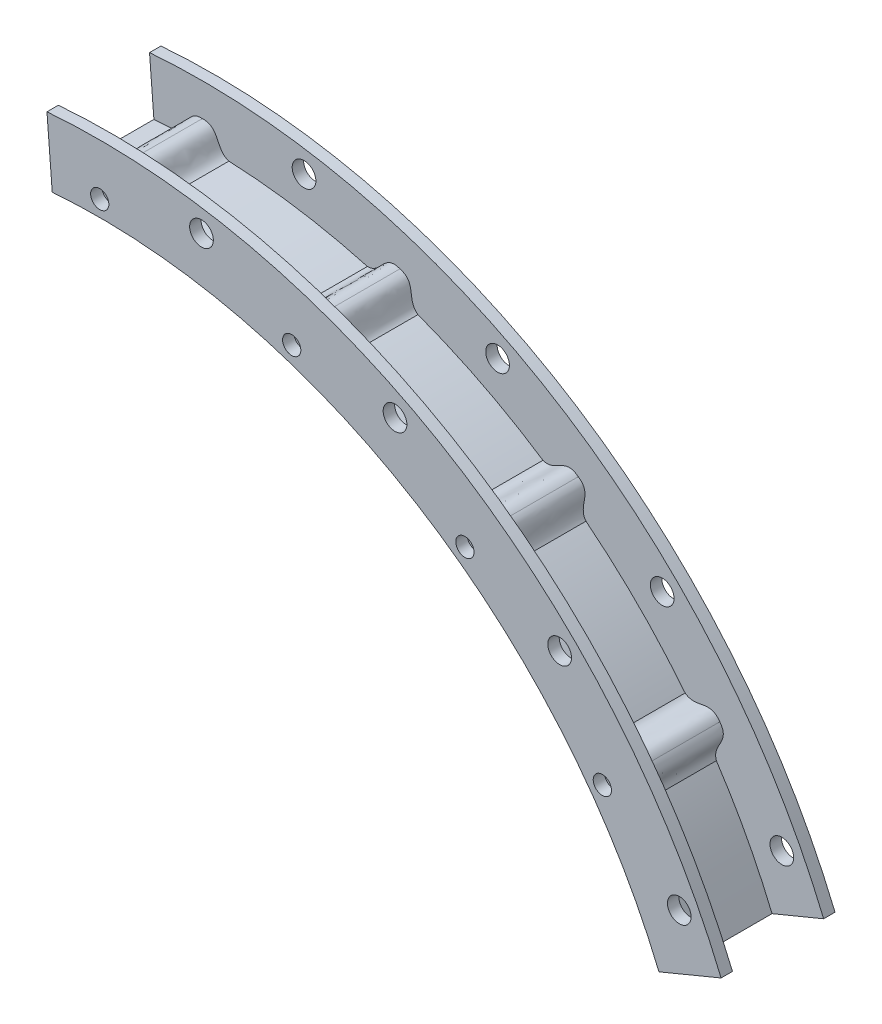
from build123d import *

# Parameters (mm, degrees)
SKETCH2_R              = 187.3885
SKETCH2_R_2            = 168.656
BOSS_EXTRUDE1_DEPTH    = 3.175
SKETCH3_R              = 171.831
SKETCH3_R_2            = 168.656
BOSS_EXTRUDE2_DEPTH    = 25.4
SKETCH4_R              = 187.3885
SKETCH4_R_2            = 168.656
BOSS_EXTRUDE3_DEPTH    = 3.175
SKETCH5_R              = 1.27
BOSS_EXTRUDE4_DEPTH    = 30.48
SKETCH6_R              = 2.54
CUT_EXTRUDE3_DEPTH     = 3.175
SKETCH7_R              = 3.302
CUT_EXTRUDE4_DEPTH     = 267.902533595
SPLIT1_SURFACE_1_BACK  = 531.965
SPLIT1_SURFACE_1_DEPTH = 1063.93


with BuildPart() as part:
    # Sketch2 → Boss-Extrude1 (new body)
    with BuildSketch(Plane.XY):
        Circle(SKETCH2_R)
        Circle(SKETCH2_R_2, mode=Mode.SUBTRACT)
    extrude(amount=BOSS_EXTRUDE1_DEPTH)

    # Sketch3 → Boss-Extrude2 (add)
    with BuildSketch(Plane.XY.offset(3.175)):
        Circle(SKETCH3_R)
        Circle(SKETCH3_R_2, mode=Mode.SUBTRACT)
    extrude(amount=BOSS_EXTRUDE2_DEPTH)

    # Sketch4 → Boss-Extrude3 (add)
    with BuildSketch(Plane.XY.offset(28.575)):
        Circle(SKETCH4_R)
        Circle(SKETCH4_R_2, mode=Mode.SUBTRACT)
    extrude(amount=BOSS_EXTRUDE3_DEPTH)

    # Sketch5 → Boss-Extrude4 (add)
    with BuildSketch(Plane.XY.offset(31.75)):
        with BuildLine():
            Line((-7.405015197, 171.671367184), (7.405015197, 171.671367184))
            add(Edge.make_bspline(
                [(0, 178.234154253), (4.961940314, 178.4344709), (3.628279784, 172.828030111), (7.405015197, 171.671367184)],
                knots=[0, 0, 0, 0, 1, 1, 1, 1], degree=3))
            add(Edge.make_bspline(
                [(0, 178.234154253), (-4.961940314, 178.4344709), (-3.628279784, 172.828030111), (-7.405015197, 171.671367184)],
                knots=[0, 0, 0, 0, 1, 1, 1, 1], degree=3))
        make_face()
        with Locations((0, 173.101)):
            Circle(SKETCH5_R, mode=Mode.SUBTRACT)
        with BuildLine():
            Line((46.006781951, 165.557447961), (60.091957864, 160.980896883))
            add(Edge.make_bspline(
                [(55.077382642, 169.510753828), (59.858369559, 168.167942399), (56.85749754, 163.248024122), (60.091957864, 160.980896883)],
                knots=[0, 0, 0, 0, 1, 1, 1, 1], degree=3))
            add(Edge.make_bspline(
                [(55.077382642, 169.510753828), (50.420198222, 171.234590163), (49.956099277, 165.490424349), (46.006781951, 165.557447961)],
                knots=[0, 0, 0, 0, 1, 1, 1, 1], degree=3))
        make_face()
        with Locations((53.491150743, 164.628834027)):
            Circle(SKETCH5_R, mode=Mode.SUBTRACT)
        with BuildLine():
            Line((94.915114734, 143.237612225), (106.89668101, 134.532494774))
            add(Edge.make_bspline(
                [(104.763407324, 144.194459768), (108.895444535, 141.439964002), (104.521107288, 137.688164116), (106.89668101, 134.532494774)],
                knots=[0, 0, 0, 0, 1, 1, 1, 1], degree=3))
            add(Edge.make_bspline(
                [(104.763407324, 144.194459768), (100.866856457, 147.27307468), (98.650427276, 141.953462812), (94.915114734, 143.237612225)],
                knots=[0, 0, 0, 0, 1, 1, 1, 1], degree=3))
        make_face()
        with Locations((101.746214957, 140.041650743)):
            Circle(SKETCH5_R, mode=Mode.SUBTRACT)
        with BuildLine():
            Line((134.532494774, 106.89668101), (143.237612225, 94.915114734))
            add(Edge.make_bspline(
                [(144.194459768, 104.763407324), (147.27307468, 100.866856457), (141.953462812, 98.650427276), (143.237612225, 94.915114734)],
                knots=[0, 0, 0, 0, 1, 1, 1, 1], degree=3))
            add(Edge.make_bspline(
                [(144.194459768, 104.763407324), (141.439964002, 108.895444535), (137.688164116, 104.521107288), (134.532494774, 106.89668101)],
                knots=[0, 0, 0, 0, 1, 1, 1, 1], degree=3))
        make_face()
        with Locations((140.041650743, 101.746214957)):
            Circle(SKETCH5_R, mode=Mode.SUBTRACT)
        with BuildLine():
            Line((160.980896883, 60.091957864), (165.557447961, 46.006781951))
            add(Edge.make_bspline(
                [(169.510753828, 55.077382642), (171.234590163, 50.420198222), (165.490424349, 49.956099277), (165.557447961, 46.006781951)],
                knots=[0, 0, 0, 0, 1, 1, 1, 1], degree=3))
            add(Edge.make_bspline(
                [(169.510753828, 55.077382642), (168.167942399, 59.858369559), (163.248024122, 56.85749754), (160.980896883, 60.091957864)],
                knots=[0, 0, 0, 0, 1, 1, 1, 1], degree=3))
        make_face()
        with Locations((164.628834027, 53.491150743)):
            Circle(SKETCH5_R, mode=Mode.SUBTRACT)
        with BuildLine():
            Line((171.671367184, 7.405015197), (171.671367184, -7.405015197))
            add(Edge.make_bspline(
                [(178.234154253, 0), (178.4344709, -4.961940314), (172.828030111, -3.628279784), (171.671367184, -7.405015197)],
                knots=[0, 0, 0, 0, 1, 1, 1, 1], degree=3))
            add(Edge.make_bspline(
                [(178.234154253, 0), (178.4344709, 4.961940314), (172.828030111, 3.628279784), (171.671367184, 7.405015197)],
                knots=[0, 0, 0, 0, 1, 1, 1, 1], degree=3))
        make_face()
        with Locations((173.101, 0)):
            Circle(SKETCH5_R, mode=Mode.SUBTRACT)
        with BuildLine():
            Line((165.557447961, -46.006781951), (160.980896883, -60.091957864))
            add(Edge.make_bspline(
                [(169.510753828, -55.077382642), (168.167942399, -59.858369559), (163.248024122, -56.85749754), (160.980896883, -60.091957864)],
                knots=[0, 0, 0, 0, 1, 1, 1, 1], degree=3))
            add(Edge.make_bspline(
                [(169.510753828, -55.077382642), (171.234590163, -50.420198222), (165.490424349, -49.956099277), (165.557447961, -46.006781951)],
                knots=[0, 0, 0, 0, 1, 1, 1, 1], degree=3))
        make_face()
        with Locations((164.628834027, -53.491150743)):
            Circle(SKETCH5_R, mode=Mode.SUBTRACT)
        with BuildLine():
            Line((143.237612225, -94.915114734), (134.532494774, -106.89668101))
            add(Edge.make_bspline(
                [(144.194459768, -104.763407324), (141.439964002, -108.895444535), (137.688164116, -104.521107288), (134.532494774, -106.89668101)],
                knots=[0, 0, 0, 0, 1, 1, 1, 1], degree=3))
            add(Edge.make_bspline(
                [(144.194459768, -104.763407324), (147.27307468, -100.866856457), (141.953462812, -98.650427276), (143.237612225, -94.915114734)],
                knots=[0, 0, 0, 0, 1, 1, 1, 1], degree=3))
        make_face()
        with Locations((140.041650743, -101.746214957)):
            Circle(SKETCH5_R, mode=Mode.SUBTRACT)
        with BuildLine():
            Line((106.89668101, -134.532494774), (94.915114734, -143.237612225))
            add(Edge.make_bspline(
                [(104.763407324, -144.194459768), (100.866856457, -147.27307468), (98.650427276, -141.953462813), (94.915114734, -143.237612225)],
                knots=[0, 0, 0, 0, 1, 1, 1, 1], degree=3))
            add(Edge.make_bspline(
                [(104.763407324, -144.194459768), (108.895444535, -141.439964002), (104.521107288, -137.688164116), (106.89668101, -134.532494774)],
                knots=[0, 0, 0, 0, 1, 1, 1, 1], degree=3))
        make_face()
        with Locations((101.746214957, -140.041650743)):
            Circle(SKETCH5_R, mode=Mode.SUBTRACT)
        with BuildLine():
            Line((60.091957864, -160.980896883), (46.006781951, -165.557447961))
            add(Edge.make_bspline(
                [(55.077382642, -169.510753828), (50.420198222, -171.234590163), (49.956099277, -165.490424349), (46.006781951, -165.557447961)],
                knots=[0, 0, 0, 0, 1, 1, 1, 1], degree=3))
            add(Edge.make_bspline(
                [(55.077382642, -169.510753828), (59.858369559, -168.167942399), (56.85749754, -163.248024122), (60.091957864, -160.980896883)],
                knots=[0, 0, 0, 0, 1, 1, 1, 1], degree=3))
        make_face()
        with Locations((53.491150743, -164.628834027)):
            Circle(SKETCH5_R, mode=Mode.SUBTRACT)
        with BuildLine():
            Line((7.405015197, -171.671367184), (-7.405015197, -171.671367184))
            add(Edge.make_bspline(
                [(0, -178.234154253), (-4.961940314, -178.4344709), (-3.628279784, -172.828030111), (-7.405015197, -171.671367184)],
                knots=[0, 0, 0, 0, 1, 1, 1, 1], degree=3))
            add(Edge.make_bspline(
                [(0, -178.234154253), (4.961940314, -178.4344709), (3.628279784, -172.828030111), (7.405015197, -171.671367184)],
                knots=[0, 0, 0, 0, 1, 1, 1, 1], degree=3))
        make_face()
        with Locations((0, -173.101)):
            Circle(SKETCH5_R, mode=Mode.SUBTRACT)
        with BuildLine():
            Line((-46.006781951, -165.557447961), (-60.091957864, -160.980896883))
            add(Edge.make_bspline(
                [(-55.077382642, -169.510753828), (-59.858369559, -168.167942399), (-56.85749754, -163.248024122), (-60.091957864, -160.980896883)],
                knots=[0, 0, 0, 0, 1, 1, 1, 1], degree=3))
            add(Edge.make_bspline(
                [(-55.077382642, -169.510753828), (-50.420198222, -171.234590163), (-49.956099277, -165.490424349), (-46.006781951, -165.557447961)],
                knots=[0, 0, 0, 0, 1, 1, 1, 1], degree=3))
        make_face()
        with Locations((-53.491150743, -164.628834027)):
            Circle(SKETCH5_R, mode=Mode.SUBTRACT)
        with BuildLine():
            Line((-94.915114734, -143.237612225), (-106.89668101, -134.532494774))
            add(Edge.make_bspline(
                [(-104.763407324, -144.194459768), (-108.895444535, -141.439964002), (-104.521107288, -137.688164116), (-106.89668101, -134.532494774)],
                knots=[0, 0, 0, 0, 1, 1, 1, 1], degree=3))
            add(Edge.make_bspline(
                [(-104.763407324, -144.194459768), (-100.866856457, -147.27307468), (-98.650427276, -141.953462812), (-94.915114734, -143.237612225)],
                knots=[0, 0, 0, 0, 1, 1, 1, 1], degree=3))
        make_face()
        with Locations((-101.746214957, -140.041650743)):
            Circle(SKETCH5_R, mode=Mode.SUBTRACT)
        with BuildLine():
            Line((-134.532494774, -106.89668101), (-143.237612225, -94.915114734))
            add(Edge.make_bspline(
                [(-144.194459768, -104.763407324), (-147.27307468, -100.866856457), (-141.953462813, -98.650427276), (-143.237612225, -94.915114734)],
                knots=[0, 0, 0, 0, 1, 1, 1, 1], degree=3))
            add(Edge.make_bspline(
                [(-144.194459768, -104.763407324), (-141.439964001, -108.895444535), (-137.688164116, -104.521107288), (-134.532494774, -106.89668101)],
                knots=[0, 0, 0, 0, 1, 1, 1, 1], degree=3))
        make_face()
        with Locations((-140.041650743, -101.746214957)):
            Circle(SKETCH5_R, mode=Mode.SUBTRACT)
        with BuildLine():
            Line((-160.980896882, -60.091957864), (-165.557447961, -46.006781951))
            add(Edge.make_bspline(
                [(-169.510753828, -55.077382642), (-171.234590163, -50.420198222), (-165.490424349, -49.956099277), (-165.557447961, -46.006781951)],
                knots=[0, 0, 0, 0, 1, 1, 1, 1], degree=3))
            add(Edge.make_bspline(
                [(-169.510753828, -55.077382642), (-168.167942399, -59.858369559), (-163.248024122, -56.85749754), (-160.980896882, -60.091957864)],
                knots=[0, 0, 0, 0, 1, 1, 1, 1], degree=3))
        make_face()
        with Locations((-164.628834027, -53.491150743)):
            Circle(SKETCH5_R, mode=Mode.SUBTRACT)
        with BuildLine():
            Line((-171.671367184, -7.405015197), (-171.671367184, 7.405015197))
            add(Edge.make_bspline(
                [(-178.234154253, 0), (-178.4344709, 4.961940314), (-172.828030111, 3.628279784), (-171.671367184, 7.405015197)],
                knots=[0, 0, 0, 0, 1, 1, 1, 1], degree=3))
            add(Edge.make_bspline(
                [(-178.234154253, 0), (-178.4344709, -4.961940314), (-172.828030111, -3.628279784), (-171.671367184, -7.405015197)],
                knots=[0, 0, 0, 0, 1, 1, 1, 1], degree=3))
        make_face()
        with Locations((-173.101, 0)):
            Circle(SKETCH5_R, mode=Mode.SUBTRACT)
        with BuildLine():
            Line((-165.557447961, 46.006781951), (-160.980896883, 60.091957864))
            add(Edge.make_bspline(
                [(-169.510753828, 55.077382642), (-168.167942399, 59.858369559), (-163.248024122, 56.85749754), (-160.980896883, 60.091957864)],
                knots=[0, 0, 0, 0, 1, 1, 1, 1], degree=3))
            add(Edge.make_bspline(
                [(-169.510753828, 55.077382642), (-171.234590163, 50.420198222), (-165.490424349, 49.956099277), (-165.557447961, 46.006781951)],
                knots=[0, 0, 0, 0, 1, 1, 1, 1], degree=3))
        make_face()
        with Locations((-164.628834027, 53.491150743)):
            Circle(SKETCH5_R, mode=Mode.SUBTRACT)
        with BuildLine():
            Line((-143.237612225, 94.915114734), (-134.532494774, 106.89668101))
            add(Edge.make_bspline(
                [(-144.194459768, 104.763407324), (-141.439964002, 108.895444535), (-137.688164116, 104.521107288), (-134.532494774, 106.89668101)],
                knots=[0, 0, 0, 0, 1, 1, 1, 1], degree=3))
            add(Edge.make_bspline(
                [(-144.194459768, 104.763407324), (-147.27307468, 100.866856457), (-141.953462812, 98.650427276), (-143.237612225, 94.915114734)],
                knots=[0, 0, 0, 0, 1, 1, 1, 1], degree=3))
        make_face()
        with Locations((-140.041650743, 101.746214957)):
            Circle(SKETCH5_R, mode=Mode.SUBTRACT)
        with BuildLine():
            Line((-106.89668101, 134.532494774), (-94.915114734, 143.237612225))
            add(Edge.make_bspline(
                [(-104.763407324, 144.194459768), (-100.866856457, 147.27307468), (-98.650427276, 141.953462812), (-94.915114734, 143.237612225)],
                knots=[0, 0, 0, 0, 1, 1, 1, 1], degree=3))
            add(Edge.make_bspline(
                [(-104.763407324, 144.194459768), (-108.895444535, 141.439964002), (-104.521107288, 137.688164116), (-106.89668101, 134.532494774)],
                knots=[0, 0, 0, 0, 1, 1, 1, 1], degree=3))
        make_face()
        with Locations((-101.746214957, 140.041650743)):
            Circle(SKETCH5_R, mode=Mode.SUBTRACT)
        with BuildLine():
            Line((-60.091957864, 160.980896883), (-46.006781951, 165.557447961))
            add(Edge.make_bspline(
                [(-55.077382642, 169.510753828), (-50.420198222, 171.234590163), (-49.956099277, 165.490424349), (-46.006781951, 165.557447961)],
                knots=[0, 0, 0, 0, 1, 1, 1, 1], degree=3))
            add(Edge.make_bspline(
                [(-55.077382642, 169.510753828), (-59.858369559, 168.167942399), (-56.85749754, 163.248024122), (-60.091957864, 160.980896883)],
                knots=[0, 0, 0, 0, 1, 1, 1, 1], degree=3))
        make_face()
        with Locations((-53.491150743, 164.628834027)):
            Circle(SKETCH5_R, mode=Mode.SUBTRACT)
    extrude(amount=-BOSS_EXTRUDE4_DEPTH)

    # Sketch6 → Cut-Extrude3 (cut)
    with BuildSketch(Plane.XY.offset(31.75)):
        with Locations((0, 173.101)):
            Circle(SKETCH6_R)
        with Locations((53.491150743, 164.628834027)):
            Circle(SKETCH6_R)
        with Locations((101.746214957, 140.041650743)):
            Circle(SKETCH6_R)
        with Locations((140.041650743, 101.746214957)):
            Circle(SKETCH6_R)
        with Locations((164.628834027, 53.491150743)):
            Circle(SKETCH6_R)
        with Locations((173.101, 0)):
            Circle(SKETCH6_R)
        with Locations((164.628834027, -53.491150743)):
            Circle(SKETCH6_R)
        with Locations((140.041650743, -101.746214957)):
            Circle(SKETCH6_R)
        with Locations((101.746214957, -140.041650743)):
            Circle(SKETCH6_R)
        with Locations((53.491150743, -164.628834027)):
            Circle(SKETCH6_R)
        with Locations((0, -173.101)):
            Circle(SKETCH6_R)
        with Locations((-53.491150743, -164.628834027)):
            Circle(SKETCH6_R)
        with Locations((-101.746214957, -140.041650743)):
            Circle(SKETCH6_R)
        with Locations((-140.041650743, -101.746214957)):
            Circle(SKETCH6_R)
        with Locations((-164.628834027, -53.491150743)):
            Circle(SKETCH6_R)
        with Locations((-173.101, 0)):
            Circle(SKETCH6_R)
        with Locations((-164.628834027, 53.491150743)):
            Circle(SKETCH6_R)
        with Locations((-140.041650743, 101.746214957)):
            Circle(SKETCH6_R)
        with Locations((-101.746214957, 140.041650743)):
            Circle(SKETCH6_R)
        with Locations((-53.491150743, 164.628834027)):
            Circle(SKETCH6_R)
    extrude(amount=-CUT_EXTRUDE3_DEPTH, mode=Mode.SUBTRACT)

    # Sketch7 → Cut-Extrude4 (cut, through all)
    with BuildSketch(Plane.XY.offset(31.75)):
        with Locations((28.350461665, 178.997770278)):
            Circle(SKETCH7_R)
        with Locations((82.276244277, 161.476221372)):
            Circle(SKETCH7_R)
        with Locations((128.148254848, 128.148254848)):
            Circle(SKETCH7_R)
        with Locations((161.476221372, 82.276244277)):
            Circle(SKETCH7_R)
        with Locations((178.997770278, 28.350461665)):
            Circle(SKETCH7_R)
        with Locations((178.997770278, -28.350461665)):
            Circle(SKETCH7_R)
        with Locations((161.476221372, -82.276244277)):
            Circle(SKETCH7_R)
        with Locations((128.148254848, -128.148254848)):
            Circle(SKETCH7_R)
        with Locations((82.276244277, -161.476221372)):
            Circle(SKETCH7_R)
        with Locations((28.350461665, -178.997770278)):
            Circle(SKETCH7_R)
        with Locations((-28.350461665, -178.997770278)):
            Circle(SKETCH7_R)
        with Locations((-82.276244277, -161.476221372)):
            Circle(SKETCH7_R)
        with Locations((-128.148254848, -128.148254848)):
            Circle(SKETCH7_R)
        with Locations((-161.476221372, -82.276244277)):
            Circle(SKETCH7_R)
        with Locations((-178.997770278, -28.350461665)):
            Circle(SKETCH7_R)
        with Locations((-178.997770278, 28.350461665)):
            Circle(SKETCH7_R)
        with Locations((-161.476221372, 82.276244277)):
            Circle(SKETCH7_R)
        with Locations((-128.148254848, 128.148254848)):
            Circle(SKETCH7_R)
        with Locations((-82.276244277, 161.476221372)):
            Circle(SKETCH7_R)
        with Locations((-28.350461665, 178.997770278)):
            Circle(SKETCH7_R)
    extrude(amount=-CUT_EXTRUDE4_DEPTH, mode=Mode.SUBTRACT)

    # Split1: cut with a surface, the side it looks to stays
    # Split1 surface: a surface, the sketch's curves swept straight by 1063.93 mm
    with BuildLine(Plane.XY.offset(31.75).offset(-SPLIT1_SURFACE_1_BACK), mode=Mode.PRIVATE) as split1_surface_1_path:
        Line((-17.084919702, 217.084487636), (0, 0))
        Line((0, 0), (201.180086017, 83.331520108))
    split1_surface_1 = Shell.extrude(split1_surface_1_path.wire(), (0 * SPLIT1_SURFACE_1_DEPTH, 0 * SPLIT1_SURFACE_1_DEPTH, 1 * SPLIT1_SURFACE_1_DEPTH))
    split(bisect_by=split1_surface_1, keep=Keep.TOP)


with BuildPart() as body_2:
    # Split2: the piece on the far side of the plane
    add(part.part)
    split(bisect_by=Plane(origin=(0, 0, 28.575), x_dir=(-1, 0, 0), z_dir=(0, 0, -1)), keep=Keep.BOTTOM)


with BuildPart() as part_1:
    add(part.part)

    # Split2
    split(bisect_by=Plane(origin=(0, 0, 28.575), x_dir=(-1, 0, 0), z_dir=(0, 0, -1)), keep=Keep.TOP)


solid = Compound([body_2.part, part_1.part])
